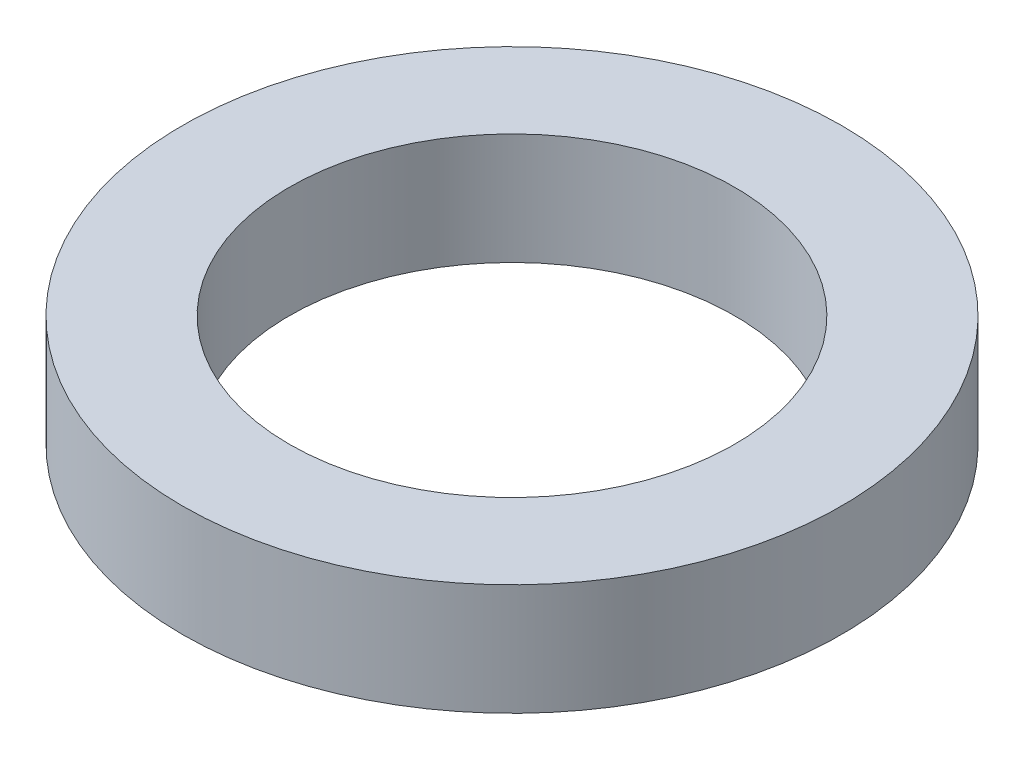
from build123d import *

# Parameters (mm, degrees)
SKETCH1_R           = 4.699
SKETCH1_R_2         = 3.175
BOSS_EXTRUDE1_DEPTH = 1.5875


with BuildPart() as part:
    # Sketch1 → Boss-Extrude1 (new body)
    with BuildSketch(Plane(origin=(0, 0, 0), x_dir=(1, 0, 0), z_dir=(0, 1, 0))):
        Circle(SKETCH1_R)
        Circle(SKETCH1_R_2, mode=Mode.SUBTRACT)
    extrude(amount=BOSS_EXTRUDE1_DEPTH)


solid = part.part
